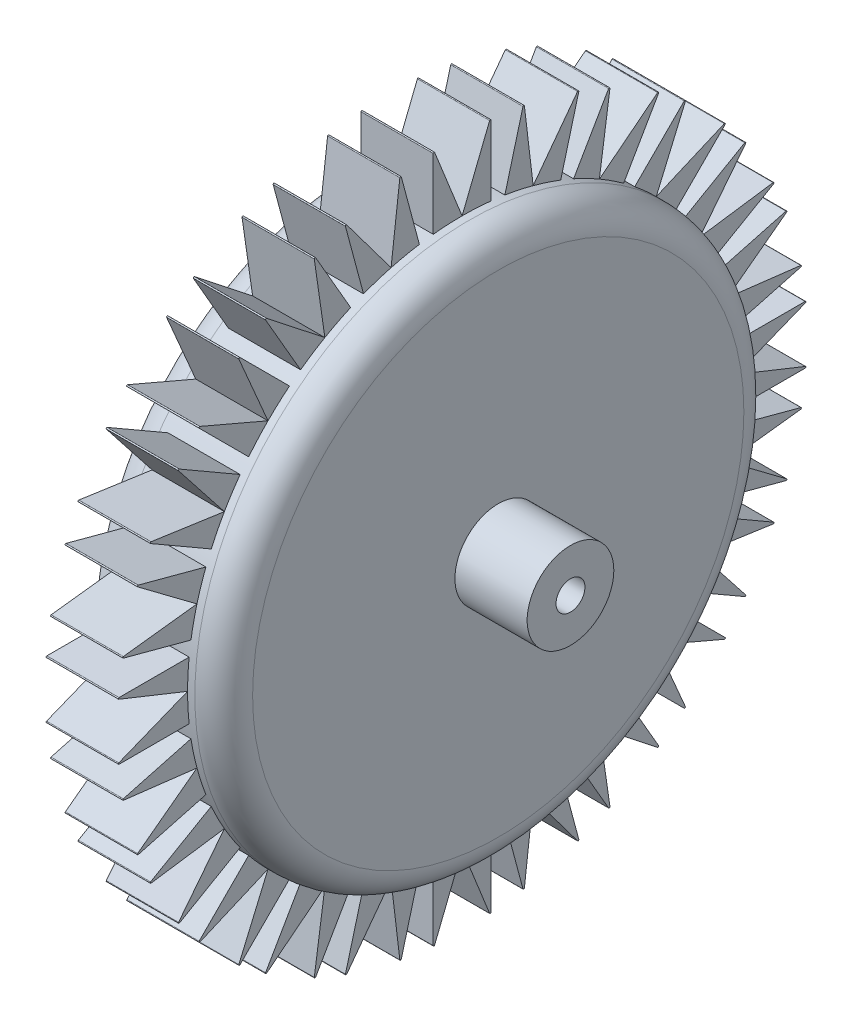
from build123d import *

# Parameters (mm, degrees)
SKETCH1_R                = 19
BOSS_EXTRUDE1_DEPTH      = 10
BOSS_EXTRUDE2_DEPTH      = 2.5
FILLET2_R                = 0.05
CIRPATTERN1_COUNT        = 24
FILLET2_OF_CIRPATTERN1_R = 0.05
FILLET1_R                = 2
BOSS_EXTRUDE3_DEPTH      = 0.5
SKETCH4_R                = 3
SKETCH4_R_2              = 1
EXTRUDE_THIN1_DEPTH      = 5


with BuildPart() as part:
    # Sketch1 → Boss-Extrude1 (new body)
    with BuildSketch(Plane(origin=(0, 0, 0), x_dir=(0, 0, -1), z_dir=(1, 0, 0))):
        Circle(SKETCH1_R)
    extrude(amount=BOSS_EXTRUDE1_DEPTH)

    # Sketch2 → Boss-Extrude2 (add, symmetric)
    with BuildSketch(Plane(origin=(5, 0, 0), x_dir=(0, 0, -1), z_dir=(1, 0, 0))):
        with BuildLine():
            ThreePointArc((-2, 18.894443628), (-1.0013918, 18.973592556), (0, 19))
            Line((0, 19), (-2, 24))
            Line((-2, 24), (-2, 18.894443628))
        make_face()
        with BuildLine():
            Line((2, 24), (0, 19))
            ThreePointArc((0, 19), (1.0013918, 18.973592556), (2, 18.894443628))
            Line((2, 18.894443628), (2, 24))
        make_face()
    boss_extrude2 = extrude(amount=BOSS_EXTRUDE2_DEPTH, both=True)

    # Fillet2
    fillet2_edges = [part.edges().sort_by_distance(p)[0] for p in [
        (5, 24, -2),
        (5, 24, 2),
    ]]
    fillet(fillet2_edges, radius=FILLET2_R)

    # CirPattern1: Boss-Extrude2 ×24 about axis
    cirpattern1_axis = Axis((0, 0, 0), (1, 0, 0))
    for i in range(1, CIRPATTERN1_COUNT):
        add(boss_extrude2.rotate(cirpattern1_axis, i * 360 / CIRPATTERN1_COUNT))

    # Fillet2 of CirPattern1
    fillet2_of_cirpattern1_edges = [part.edges().sort_by_distance(p)[0] for p in [
        (5, 23.699857921, 4.27980543),
        (5, 22.664581741, 8.143508735),
        (5, 21.784609691, 10.267949192),
        (5, 19.784609691, 13.732050808),
        (5, 18.384776311, 15.556349186),
        (5, 15.556349186, 18.384776311),
        (5, 13.732050808, 19.784609691),
        (5, 10.267949192, 21.784609691),
        (5, 8.143508735, 22.664581741),
        (5, 4.27980543, 23.699857921),
        (5, 2, 24),
        (5, -2, 24),
        (5, -4.27980543, 23.699857921),
        (5, -8.143508735, 22.664581741),
        (5, -10.267949192, 21.784609691),
        (5, -13.732050808, 19.784609691),
        (5, -15.556349186, 18.384776311),
        (5, -18.384776311, 15.556349186),
        (5, -19.784609691, 13.732050808),
        (5, -21.784609691, 10.267949192),
        (5, -22.664581741, 8.143508735),
        (5, -23.699857921, 4.27980543),
        (5, -24, 2),
        (5, -24, -2),
        (5, -23.699857921, -4.27980543),
        (5, -22.664581741, -8.143508735),
        (5, -21.784609691, -10.267949192),
        (5, -19.784609691, -13.732050808),
        (5, -18.384776311, -15.556349186),
        (5, -15.556349186, -18.384776311),
        (5, -13.732050808, -19.784609691),
        (5, -10.267949192, -21.784609691),
        (5, -8.143508735, -22.664581741),
        (5, -4.27980543, -23.699857921),
        (5, -2, -24),
        (5, 2, -24),
        (5, 4.27980543, -23.699857921),
        (5, 8.143508735, -22.664581741),
        (5, 10.267949192, -21.784609691),
        (5, 13.732050808, -19.784609691),
        (5, 15.556349186, -18.384776311),
        (5, 18.384776311, -15.556349186),
        (5, 19.784609691, -13.732050808),
        (5, 21.784609691, -10.267949192),
        (5, 22.664581741, -8.143508735),
        (5, 23.699857921, -4.27980543),
    ]]
    fillet(fillet2_of_cirpattern1_edges, radius=FILLET2_OF_CIRPATTERN1_R)

    # Fillet1
    fillet1_edges = [part.edges().sort_by_distance(p)[0] for p in [
        (0, 0, 19),
        (10, 0, 19),
    ]]
    fillet(fillet1_edges, radius=FILLET1_R)

    # Sketch3 → Boss-Extrude3 (add)
    with BuildSketch(Plane.ZY):
        Polygon((-12.685945588, 4.892681676), (-5.018648253, -1.336250453), (-8.573389566, -10.553129431), (-0.279997898, -5.185942223), (7.387299437, -11.414874352), (4.845600035, -1.868838104), (13.138991704, 3.498349104), (3.274743416, 4.030936755), (0.733044013, 13.576973003), (-2.8216973, 4.360094025), align=None)
    extrude(amount=BOSS_EXTRUDE3_DEPTH)

    # Sketch4 → Extrude-Thin1 (add)
    with BuildSketch(Plane(origin=(10, 0, 0), x_dir=(0, 0, -1), z_dir=(1, 0, 0))):
        Circle(SKETCH4_R)
        Circle(SKETCH4_R_2, mode=Mode.SUBTRACT)
    extrude(amount=EXTRUDE_THIN1_DEPTH)


solid = part.part
